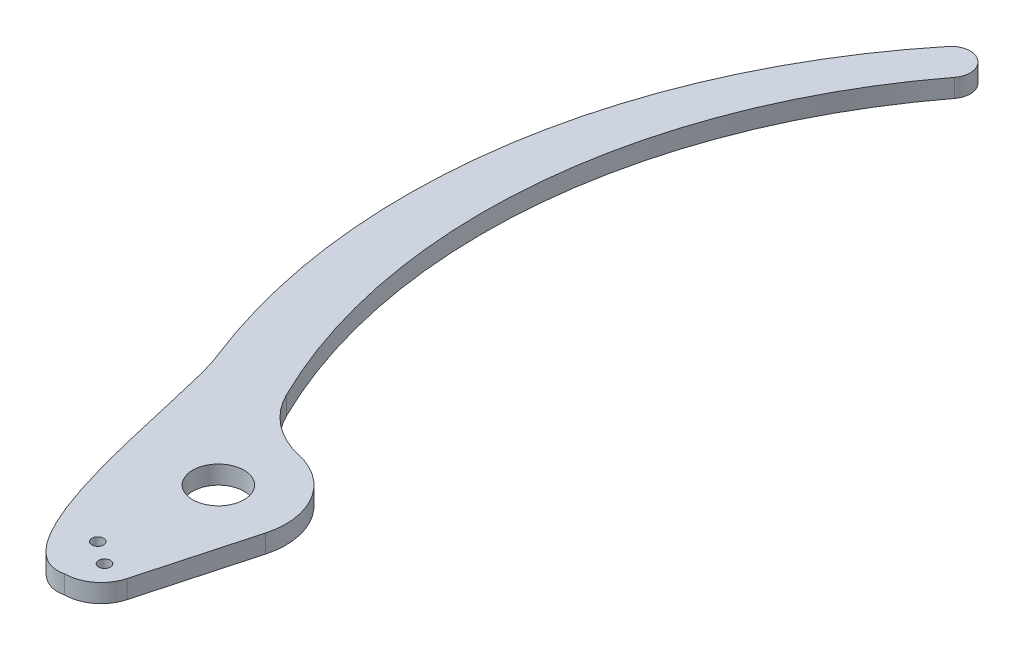
from build123d import *

# Parameters (mm, degrees)
SKETCH1_R           = 4.445
SKETCH1_R_2         = 1.016
BOSS_EXTRUDE1_DEPTH = 3.175


with BuildPart() as part:
    # Sketch1 → Boss-Extrude1 (new body)
    with BuildSketch(Plane.XZ.offset(3.175)):
        with BuildLine():
            Line((11.303, 3.096915559), (6.124282058, 21.997995611))
            ThreePointArc((6.124282058, 21.997995611), (3.851443098, 25.368651906), (0, 26.67))
            add(Edge.make_bspline(
                [(0, 26.67), (-11.245352648, 29.382878564), (-15.981518953, -11.110422608), (-19.534193398, -19.411722699)],
                knots=[0, 0, 0, 0, 1, 1, 1, 1], degree=3))
            ThreePointArc((-19.534193398, -19.411722699), (-25.928156212, -76.551612234), (-2.56021484, -129.085306685))
            ThreePointArc((-2.56021484, -129.085306685), (2.045015617, -129.592511355), (2.624173857, -124.99577557))
            ThreePointArc((2.624173857, -124.99577557), (-17.550677185, -73.664226625), (-7.62, -19.411722699))
            ThreePointArc((-7.62, -19.411722699), (-3.445364163, -14.272335011), (2.54, -11.441026832))
            ThreePointArc((2.54, -11.441026832), (10.037186084, -6.050090122), (11.303, 3.096915559))
        make_face()
        with Locations(Location((0, 0, 0), (0, 0, 90))):  # turned: the seam where the file's is
            Circle(SKETCH1_R, mode=Mode.SUBTRACT)
        with Locations(Location((-1.950605805, 18.954171111, 0), (0, 0, 90))):  # turned: the seam where the file's is
            Circle(SKETCH1_R_2, mode=Mode.SUBTRACT)
        with Locations(Location((1.950605805, 21.685828889, 0), (0, 0, 90))):  # turned: the seam where the file's is
            Circle(SKETCH1_R_2, mode=Mode.SUBTRACT)
    extrude(amount=-BOSS_EXTRUDE1_DEPTH)


solid = part.part
